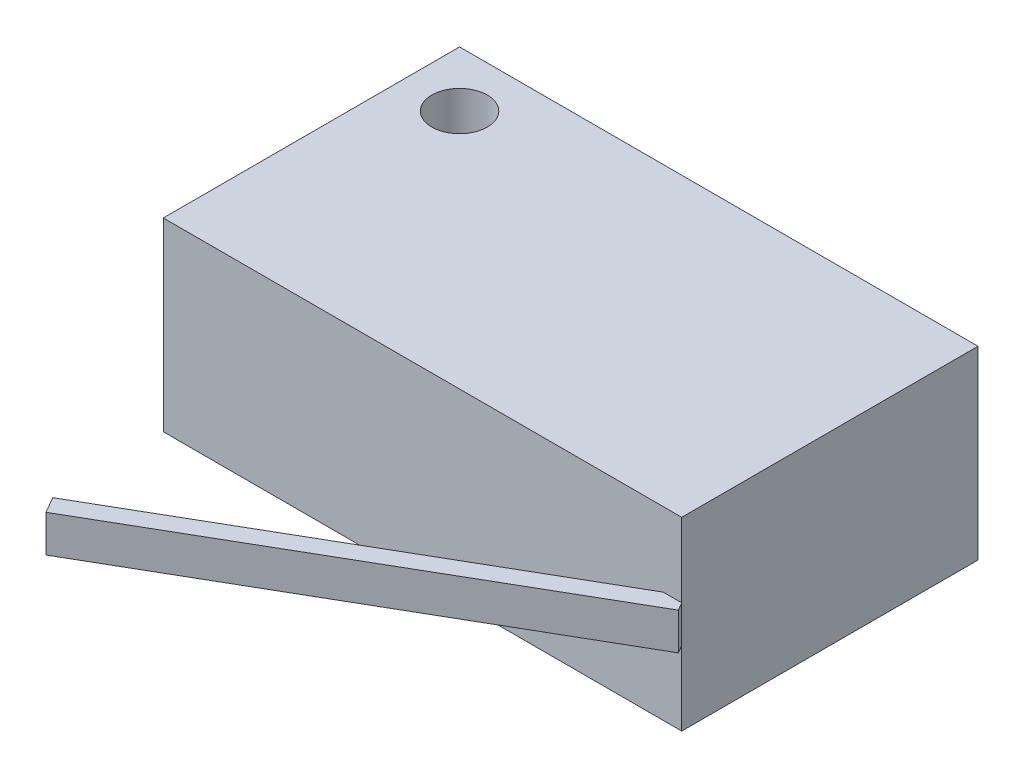
from build123d import *

# Parameters (mm, degrees)
SKETCH1_W           = 28
SKETCH1_H           = 16
BOSS_EXTRUDE1_DEPTH = 10
SKETCH2_W           = 2
SKETCH2_H           = 25
BOSS_EXTRUDE2_DEPTH = 0.5
SKETCH3_R           = 1.5
CUT_EXTRUDE1_DEPTH  = 10


with BuildPart() as part:
    # Sketch1 → Boss-Extrude1 (new body)
    with BuildSketch(Plane(origin=(0, 0, 0), x_dir=(1, 0, 0), z_dir=(0, 1, 0))):
        Rectangle(SKETCH1_W, SKETCH1_H)
    extrude(amount=BOSS_EXTRUDE1_DEPTH)

    # Sketch2 → Boss-Extrude2 (add, symmetric)
    with BuildSketch(Plane(origin=(6.964101615, 0, 12.062177826), x_dir=(0, -1, 0), z_dir=(0.5, 0, 0.866025404))):
        with Locations((-5, -4.375644347)):
            Rectangle(SKETCH2_W, SKETCH2_H)
    extrude(amount=BOSS_EXTRUDE2_DEPTH, both=True)

    # Sketch3 → Cut-Extrude1 (cut)
    with BuildSketch(Plane(origin=(0, 10, 0), x_dir=(1, 0, 0), z_dir=(0, 1, 0))):
        with Locations((-11, 5)):
            Circle(SKETCH3_R)
    extrude(amount=-CUT_EXTRUDE1_DEPTH, mode=Mode.SUBTRACT)


solid = part.part
